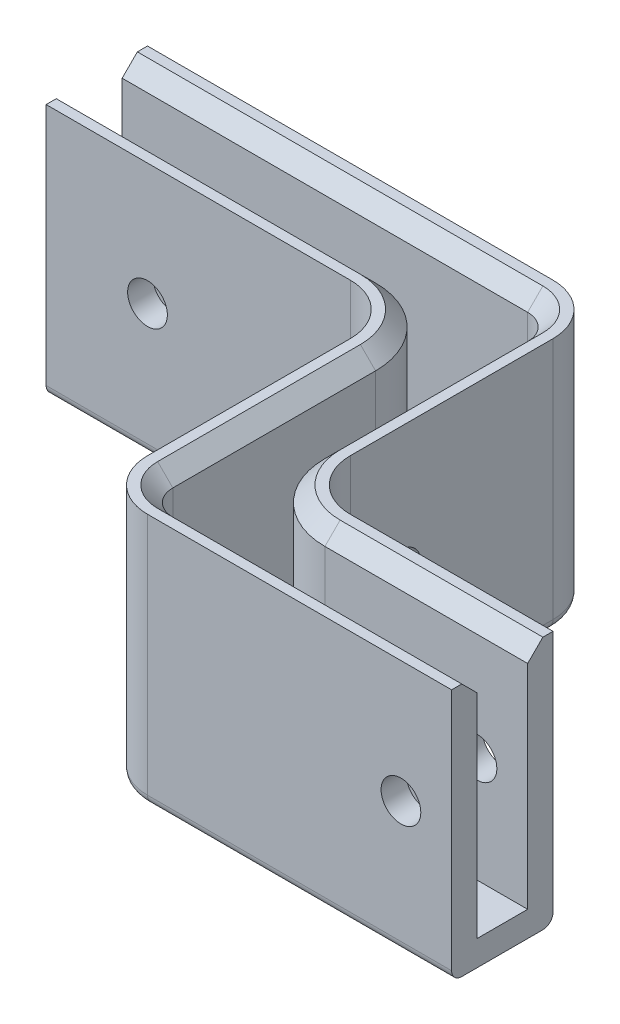
from build123d import *

# Parameters (mm, degrees)
BOSS_EXTRUDE1_DEPTH        = 31.75
FILLET1_R                  = 6.35
SHELL1_T                   = -3.175
FILLET2_R                  = 1.27
CHAMFER1_SIZE              = 1.905
F_9_0_196_DIAMETER_HOLE1_D = 4.9784
F_9_0_196_DIAMETER_HOLE2_D = 4.9784
F_9_0_196_DIAMETER_HOLE3_D = 4.9784


with BuildPart() as part:
    # Sketch1 → Boss-Extrude1 (new body)
    with BuildSketch(Plane(origin=(0, 0, 0), x_dir=(1, 0, 0), z_dir=(0, 1, 0))):
        Polygon((-57.15, 0), (0, 0), (0, -38.1), (31.75, -38.1), (31.75, -50.8), (-12.7, -50.8), (-12.7, -12.7), (-57.15, -12.7), align=None)
    extrude(amount=BOSS_EXTRUDE1_DEPTH)

    # Fillet1
    fillet1_edges = [part.edges().sort_by_distance(p)[0] for p in [
        (0, 15.875, 0),
        (0, 15.875, 38.1),
        (-12.7, 15.875, 50.8),
        (-12.7, 15.875, 12.7),
    ]]
    fillet(fillet1_edges, radius=FILLET1_R)

    # Shell1
    shell1_openings = [part.faces().sort_by_distance(p)[0] for p in [
        (-8.466666667, 31.75, 25.4),
        (31.75, 15.875, 44.45),
        (-57.15, 15.875, 6.35),
    ]]
    offset(amount=SHELL1_T, openings=shell1_openings, kind=Kind.INTERSECTION)

    # Fillet2
    fillet2_edges = [part.edges().sort_by_distance(p)[0] for p in [
        (-38.1, 0, 12.7),
        (12.7, 0, 50.8),
        (-31.75, 0, 0),
        (0, 0, 19.05),
        (-12.7, 0, 31.75),
        (-1.859871939, 0, 1.859871939),
        (-10.840128061, 0, 48.940128061),
        (-14.559871939, 0, 14.559871939),
        (1.859871939, 0, 36.240128061),
        (19.05, 0, 38.1),
    ]]
    fillet(fillet2_edges, radius=FILLET2_R)

    # Chamfer1
    chamfer1_edges = [part.edges().sort_by_distance(p)[0] for p in [
        (-9.525, 31.75, 31.75),
        (-8.59506403, 31.75, 46.69506403),
        (12.7, 31.75, 47.625),
        (19.05, 31.75, 41.275),
        (-0.385192091, 31.75, 38.485192091),
        (-3.175, 31.75, 19.05),
        (-4.10493597, 31.75, 4.10493597),
        (-31.75, 31.75, 3.175),
        (-38.1, 31.75, 9.525),
        (-12.314807909, 31.75, 12.314807909),
    ]]
    chamfer(chamfer1_edges, length=CHAMFER1_SIZE)

    # #9 (0.196) Diameter Hole1 (through all)
    with Locations(Plane.ZY.offset(12.7)):
        with Locations((25.4, 15.875)):
            Hole(F_9_0_196_DIAMETER_HOLE1_D / 2)

    # #9 (0.196) Diameter Hole2 (through all)
    with Locations(Plane(origin=(0, 0, 0), x_dir=(-1, 0, 0), z_dir=(0, 0, -1))):
        with Locations((44.45, 16.51)):
            Hole(F_9_0_196_DIAMETER_HOLE2_D / 2)

    # #9 (0.196) Diameter Hole3 (through all)
    with Locations(Plane.XY.offset(50.8)):
        with Locations((25.4, 16.51)):
            Hole(F_9_0_196_DIAMETER_HOLE3_D / 2)


solid = part.part
